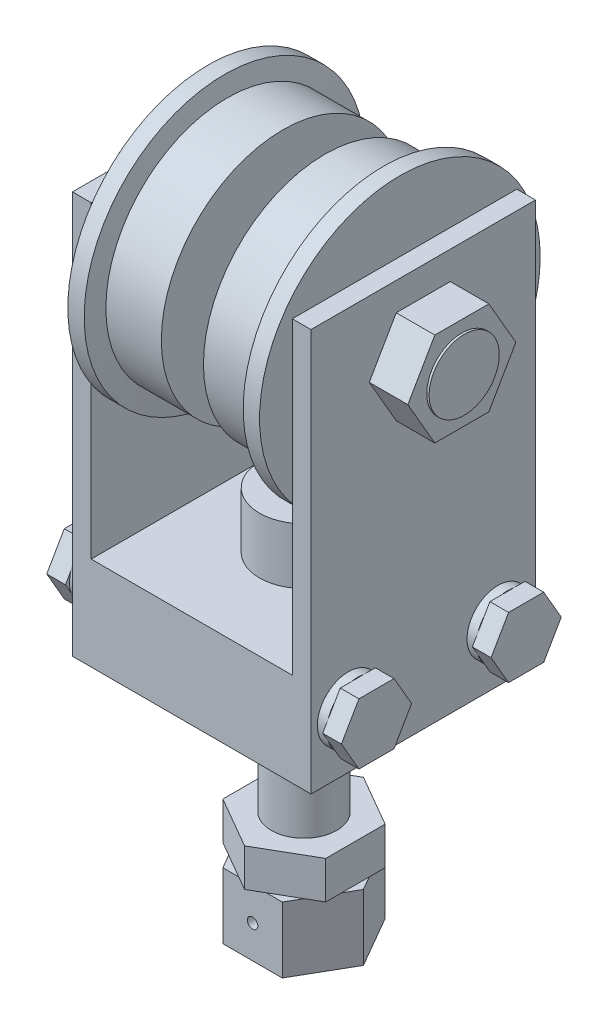
from build123d import *

# Parameters (mm, degrees)
YOKE_CROSS_SECTION_W           = 152.4
YOKE_CROSS_SECTION_H           = 63.5
YOKE_DEPTH                     = 68.2625
SIDEPLATE_PROFILE_W            = 152.4
SIDEPLATE_PROFILE_H            = 273.05
SIDEPLATE_DEPTH                = 12.7
WHEEL_PIN_NUT_DEPTH            = 26.19375
WHEEL_PIN_PROJECTION_PROFILE_R = 23.8125
WHEEL_PIN_PROJECTION_DEPTH     = 1.5875
LOCKNUTS_PROFILE_R             = 21.0947
LOCKNUTS_DEPTH                 = 6.35
SCREWS_DEPTH                   = 12.7
PROFILE_R                      = 30.1625
KING_BOLT_HEAD_DEPTH           = 38.1
DIA_R                          = 22.225
KING_BOLT_DEPTH                = 88.9
KING_BOLT_JAM_NUT_DEPTH        = 25.6286
KING_BOLT_NUT_DEPTH            = 44.6786
SKETCH5_R                      = 22.225
EXTENDED_KING_BOLT_DEPTH       = 9.525
CHAMFER1_SIZE                  = 2.38125
COTTER_PIN_HOLE_REACH          = 132.175
SKETCH7_R                      = 3.571875
SKETCH8_R                      = 30.1625
SKETCH8_R_2                    = 25.4
SPACER_DEPTH                   = 12.7


with BuildPart() as part:
    # YOKE CROSS SECTION → YOKE (new body)
    with BuildSketch(Plane(origin=(0, 0, 0), x_dir=(0, 0, -1), z_dir=(1, 0, 0))):
        with Locations((0, 31.75)):
            Rectangle(YOKE_CROSS_SECTION_W, YOKE_CROSS_SECTION_H)
    extrude(amount=YOKE_DEPTH)

    # SIDEPLATE PROFILE → SIDEPLATE (add)
    with BuildSketch(Plane(origin=(68.2625, 0, 0), x_dir=(0, 0, -1), z_dir=(1, 0, 0))):
        with Locations((0, 136.525)):
            Rectangle(SIDEPLATE_PROFILE_W, SIDEPLATE_PROFILE_H)
    extrude(amount=SIDEPLATE_DEPTH)

    # WHEEL PIN NUT PROFILE → WHEEL PIN NUT (add)
    with BuildSketch(Plane(origin=(80.9625, 0, 0), x_dir=(0, 0, -1), z_dir=(1, 0, 0))):
        Polygon((36.661742094, 222.25), (18.330871047, 254), (-18.330871047, 254), (-36.661742094, 222.25), (-18.330871047, 190.5), (18.330871047, 190.5), align=None)
    extrude(amount=WHEEL_PIN_NUT_DEPTH)

    # WHEEL PIN PROJECTION PROFILE → WHEEL PIN PROJECTION (add)
    with BuildSketch(Plane(origin=(107.15625, 0, 0), x_dir=(0, 0, -1), z_dir=(1, 0, 0))):
        with Locations((0, 222.25)):
            Circle(WHEEL_PIN_PROJECTION_PROFILE_R)
    extrude(amount=WHEEL_PIN_PROJECTION_DEPTH)

    # LOCKNUTS PROFILE → LOCKNUTS (add)
    with BuildSketch(Plane(origin=(80.9625, 0, 0), x_dir=(0, 0, -1), z_dir=(1, 0, 0))):
        with Locations((-50.8, 38.1)):
            Circle(LOCKNUTS_PROFILE_R)
    locknuts = extrude(amount=LOCKNUTS_DEPTH)

    # SCREWS PROFILE → SCREWS (add)
    with BuildSketch(Plane(origin=(87.3125, 0, 0), x_dir=(0, 0, -1), z_dir=(1, 0, 0))):
        Polygon((-26.969867639, 38.1), (-38.88493382, 58.7375), (-62.71506618, 58.7375), (-74.630132361, 38.1), (-62.71506618, 17.4625), (-38.88493382, 17.4625), align=None)
    screws = extrude(amount=SCREWS_DEPTH)

    # PROFILE → KING BOLT HEAD (add)
    with BuildSketch(Plane(origin=(0, 63.5, 0), x_dir=(-1, 0, 0), z_dir=(0, 1, 0))):
        with Locations(Location((0, 0, 0), (0, 0, 90))):  # turned: the seam where the file's is
            Circle(PROFILE_R)
    extrude(amount=KING_BOLT_HEAD_DEPTH)

    # Mirror1: LOCKNUTS, SCREWS across plane
    add(locknuts.mirror(Plane.XY))
    add(screws.mirror(Plane.XY))

    # Mirror5: part across plane


with BuildPart() as part_1:
    add(part.part)
    add(part.part.mirror(Plane(origin=(0, 0, 0), x_dir=(0, 0, 1), z_dir=(1, 0, 0))))

    # DIA. → KING BOLT (add)
    with BuildSketch(Plane.XZ):
        with Locations(Location((0, 0, 0), (0, 0, 90))):  # turned: the seam where the file's is
            Circle(DIA_R)
    extrude(amount=KING_BOLT_DEPTH)

    # KING BOLT JAN NUT PROFILE → KING BOLT JAM NUT (add)
    with BuildSketch(Plane.XZ.offset(88.9)):
        Polygon((0, -40.327916303), (34.925, -20.163958151), (34.925, 20.163958151), (0, 40.327916303), (-34.925, 20.163958151), (-34.925, -20.163958151), align=None)
    extrude(amount=KING_BOLT_JAM_NUT_DEPTH)

    # KING BOLT NUT PROFILE → KING BOLT NUT (add)
    with BuildSketch(Plane.XZ.offset(114.5286)):
        Polygon((40.327916303, 0), (20.163958151, 34.925), (-20.163958151, 34.925), (-40.327916303, 0), (-20.163958151, -34.925), (20.163958151, -34.925), align=None)
    extrude(amount=KING_BOLT_NUT_DEPTH)

    # Sketch5 → EXTENDED KING BOLT (add)
    with BuildSketch(Plane.XZ.offset(159.2072)):
        with Locations(Location((0, 0, 0), (0, 0, 90))):  # turned: the seam where the file's is
            Circle(SKETCH5_R)
    extrude(amount=EXTENDED_KING_BOLT_DEPTH)

    # Chamfer1
    chamfer1_edges = [part_1.edges().sort_by_distance(p)[0] for p in [
        (0, -168.7322, -22.225),
    ]]
    chamfer(chamfer1_edges, length=CHAMFER1_SIZE)

    # Sketch6 → WHEEL (revolve)
    with BuildSketch(Plane.XY, mode=Mode.PRIVATE) as wheel_sk:
        Polygon((51.963517608, 304.8), (53.975, 317.5), (65.0875, 317.5), (65.0875, 254), (68.2625, 254), (68.2625, 222.25), (14.2875, 222.25), (14.2875, 304.8), align=None)
    wheel = revolve(wheel_sk.sketch.rotate(Axis((68.2625, 222.25, 0), (-1, 0, 0)), 90), axis=Axis((68.2625, 222.25, 0), (-1, 0, 0)))  # turned: the seam where the file's is

    # Mirror6: WHEEL across plane
    add(wheel.mirror(Plane(origin=(0, 0, 0), x_dir=(0, 0, 1), z_dir=(1, 0, 0))))

    # Sketch7 → COTTER PIN HOLE (cut, up to next)
    with BuildSketch(Plane.XY.offset(34.925), mode=Mode.PRIVATE) as cotter_pin_hole_sk1:
        with Locations((0, -136.9822)):
            Circle(SKETCH7_R)
    cotter_pin_hole_tool1 = extrude(cotter_pin_hole_sk1.sketch, amount=-COTTER_PIN_HOLE_REACH, mode=Mode.PRIVATE) & part_1.part
    add(cotter_pin_hole_tool1.solids().sort_by_distance((0, -136.9822, 34.925))[0], mode=Mode.SUBTRACT)

    # Sketch8 → SPACER (add)
    with BuildSketch(Plane.XZ):
        with Locations(Location((0, 0, 0), (0, 0, 90))):  # turned: the seam where the file's is
            Circle(SKETCH8_R)
        with Locations(Location((0, 0, 0), (0, 0, 270))):  # turned: the seam where the file's is
            Circle(SKETCH8_R_2, mode=Mode.SUBTRACT)
    extrude(amount=SPACER_DEPTH)


solid = part_1.part
